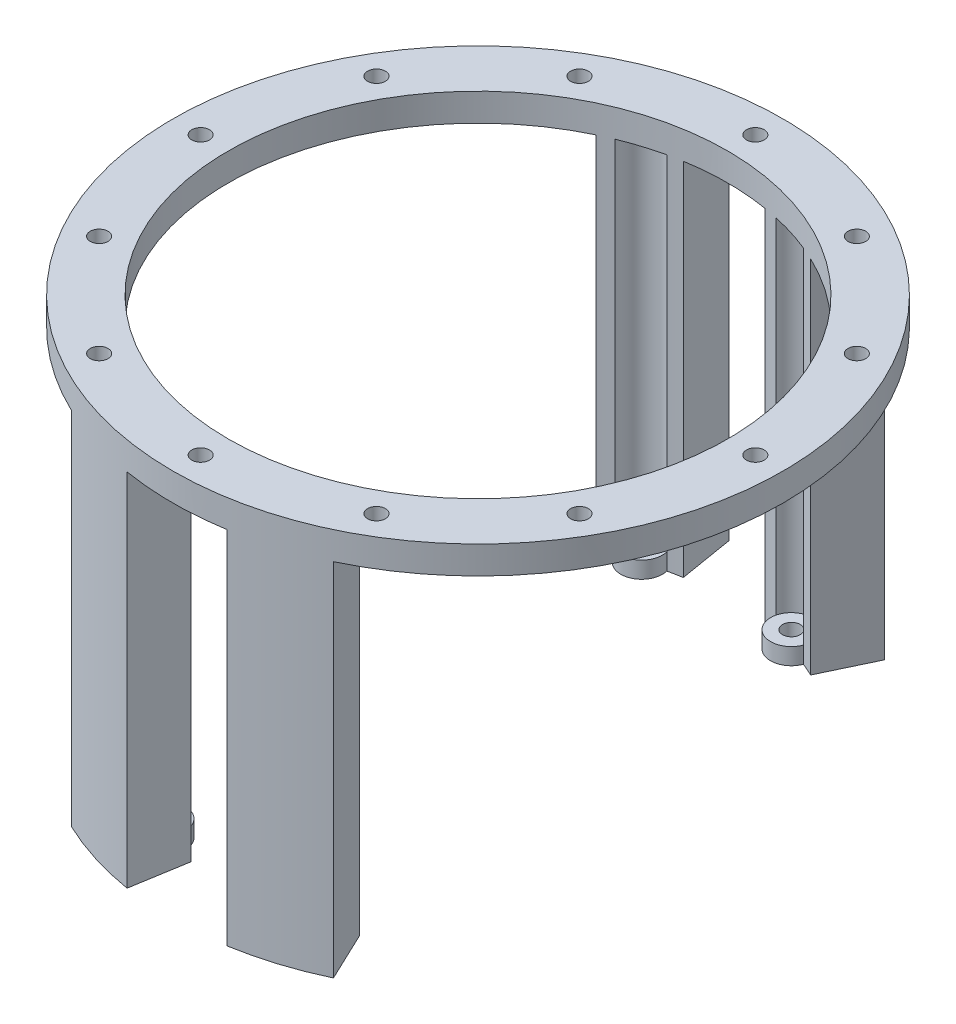
from build123d import *
from build123d.topology import SkipClean

# Parameters (mm, degrees)
SKETCH1_R             = 3.75
SKETCH1_R_2           = 1.6
BOSS_EXTRUDE3_DEPTH   = 3
BOSS_EXTRUDE3_2_DEPTH = 3
BOSS_EXTRUDE3_3_DEPTH = 3
BOSS_EXTRUDE3_4_DEPTH = 3
BOSS_EXTRUDE4_DEPTH   = 65
SKETCH3_R             = 55
SKETCH3_R_2           = 45
SKETCH3_R_3           = 1.6
BOSS_EXTRUDE5_DEPTH   = 5


with BuildPart() as part:
    # Sketch1 → Boss-Extrude3 (new body)
    with BuildSketch(Plane(origin=(0, 0, 0), x_dir=(1, 0, 0), z_dir=(0, 1, 0))):
        with Locations((-13.5, -43)):
            Circle(SKETCH1_R)
        with Locations((-13.5, -43)):
            Circle(SKETCH1_R_2, mode=Mode.SUBTRACT)
    extrude(amount=BOSS_EXTRUDE3_DEPTH)



with BuildPart() as body_2:
    # Sketch1 → Boss-Extrude3 2 (new body)
    with BuildSketch(Plane(origin=(0, 0, 0), x_dir=(1, 0, 0), z_dir=(0, 1, 0))):
        with Locations((13.5, -43)):
            Circle(SKETCH1_R)
        with Locations((13.5, -43)):
            Circle(SKETCH1_R_2, mode=Mode.SUBTRACT)
    extrude(amount=BOSS_EXTRUDE3_2_DEPTH)


with BuildPart() as body_3:
    # Sketch1 → Boss-Extrude3 3 (new body)
    with BuildSketch(Plane(origin=(0, 0, 0), x_dir=(1, 0, 0), z_dir=(0, 1, 0))):
        with Locations((-13.5, 43)):
            Circle(SKETCH1_R)
        with Locations((-13.5, 43)):
            Circle(SKETCH1_R_2, mode=Mode.SUBTRACT)
    extrude(amount=BOSS_EXTRUDE3_3_DEPTH)


with BuildPart() as body_4:
    # Sketch1 → Boss-Extrude3 4 (new body)
    with BuildSketch(Plane(origin=(0, 0, 0), x_dir=(1, 0, 0), z_dir=(0, 1, 0))):
        with Locations((13.5, 43)):
            Circle(SKETCH1_R)
        with Locations((13.5, 43)):
            Circle(SKETCH1_R_2, mode=Mode.SUBTRACT)
    extrude(amount=BOSS_EXTRUDE3_4_DEPTH)


with BuildPart() as part_1:
    add(part.part)

    add(body_2.part)  # Boss-Extrude4 merges body 2

    add(body_3.part)  # Boss-Extrude4 merges body 3

    add(body_4.part)  # Boss-Extrude4 merges body 4
    # Sketch1_7 → Boss-Extrude4 (add)
    with BuildSketch(Plane(origin=(0, 0, 0), x_dir=(1, 0, 0), z_dir=(0, 1, 0))):
        with BuildLine():
            ThreePointArc((-9.861149523, -43.906237941), (-14.623267897, -46.577816266), (-17.003850477, -41.663762059))
            ThreePointArc((-17.003850477, -41.663762059), (-18.170769041, -41.168229892), (-19.323265389, -40.640022327))
            Line((-19.323265389, -40.640022327), (-23.617324364, -49.671138399))
            ThreePointArc((-23.617324364, -49.671138399), (-16.474595828, -52.474638563), (-9.011208023, -54.256779576))
            Line((-9.011208023, -54.256779576), (-7.372806564, -44.391910562))
            ThreePointArc((-7.372806564, -44.391910562), (-8.620399067, -44.166601861), (-9.861149523, -43.906237941))
        make_face()
        with BuildLine():
            ThreePointArc((19.323265389, -40.640022327), (18.170769041, -41.168229892), (17.003850477, -41.663762059))
            ThreePointArc((17.003850477, -41.663762059), (14.623267897, -46.577816266), (9.861149523, -43.906237941))
            ThreePointArc((9.861149523, -43.906237941), (8.620399067, -44.166601861), (7.372806564, -44.391910562))
            Line((7.372806564, -44.391910562), (9.011208023, -54.256779576))
            ThreePointArc((9.011208023, -54.256779576), (16.474595828, -52.474638563), (23.617324364, -49.671138399))
            Line((23.617324364, -49.671138399), (19.323265389, -40.640022327))
        make_face()
        with BuildLine():
            Line((-23.617324364, 49.671138399), (-19.323265389, 40.640022327))
            ThreePointArc((-19.323265389, 40.640022327), (-18.170769041, 41.168229892), (-17.003850477, 41.663762059))
            ThreePointArc((-17.003850477, 41.663762059), (-14.623267897, 46.577816266), (-9.861149523, 43.906237941))
            ThreePointArc((-9.861149523, 43.906237941), (-8.620399067, 44.166601861), (-7.372806564, 44.391910562))
            Line((-7.372806564, 44.391910562), (-9.011208023, 54.256779576))
            ThreePointArc((-9.011208023, 54.256779576), (-16.474595828, 52.474638563), (-23.617324364, 49.671138399))
        make_face()
        with BuildLine():
            ThreePointArc((17.003850477, 41.663762059), (18.170769041, 41.168229892), (19.323265389, 40.640022327))
            Line((19.323265389, 40.640022327), (23.617324364, 49.671138399))
            ThreePointArc((23.617324364, 49.671138399), (16.474595828, 52.474638563), (9.011208023, 54.256779576))
            Line((9.011208023, 54.256779576), (7.372806564, 44.391910562))
            ThreePointArc((7.372806564, 44.391910562), (8.620399067, 44.166601861), (9.861149523, 43.906237941))
            ThreePointArc((9.861149523, 43.906237941), (14.623267897, 46.577816266), (17.003850477, 41.663762059))
        make_face()
    extrude(amount=BOSS_EXTRUDE4_DEPTH)

    # Sketch3 → Boss-Extrude5 (add)
    with SkipClean():  # the faces are left unmerged after this step: merging them gives an invalid solid
        with BuildSketch(Plane(origin=(0, 65, 0), x_dir=(1, 0, 0), z_dir=(0, 1, 0))):
            Circle(SKETCH3_R)
            Circle(SKETCH3_R_2, mode=Mode.SUBTRACT)
            with Locations((0, 50)):
                Circle(SKETCH3_R_3, mode=Mode.SUBTRACT)
            with Locations((25, 43.301270189)):
                Circle(SKETCH3_R_3, mode=Mode.SUBTRACT)
            with Locations((43.301270189, 25)):
                Circle(SKETCH3_R_3, mode=Mode.SUBTRACT)
            with Locations((50, 0)):
                Circle(SKETCH3_R_3, mode=Mode.SUBTRACT)
            with Locations((43.301270189, -25)):
                Circle(SKETCH3_R_3, mode=Mode.SUBTRACT)
            with Locations((25, -43.301270189)):
                Circle(SKETCH3_R_3, mode=Mode.SUBTRACT)
            with Locations((0, -50)):
                Circle(SKETCH3_R_3, mode=Mode.SUBTRACT)
            with Locations((-25, -43.301270189)):
                Circle(SKETCH3_R_3, mode=Mode.SUBTRACT)
            with Locations((-43.301270189, -25)):
                Circle(SKETCH3_R_3, mode=Mode.SUBTRACT)
            with Locations((-50, 0)):
                Circle(SKETCH3_R_3, mode=Mode.SUBTRACT)
            with Locations((-43.301270189, 25)):
                Circle(SKETCH3_R_3, mode=Mode.SUBTRACT)
            with Locations((-25, 43.301270189)):
                Circle(SKETCH3_R_3, mode=Mode.SUBTRACT)
        extrude(amount=BOSS_EXTRUDE5_DEPTH)


solid = part_1.part
